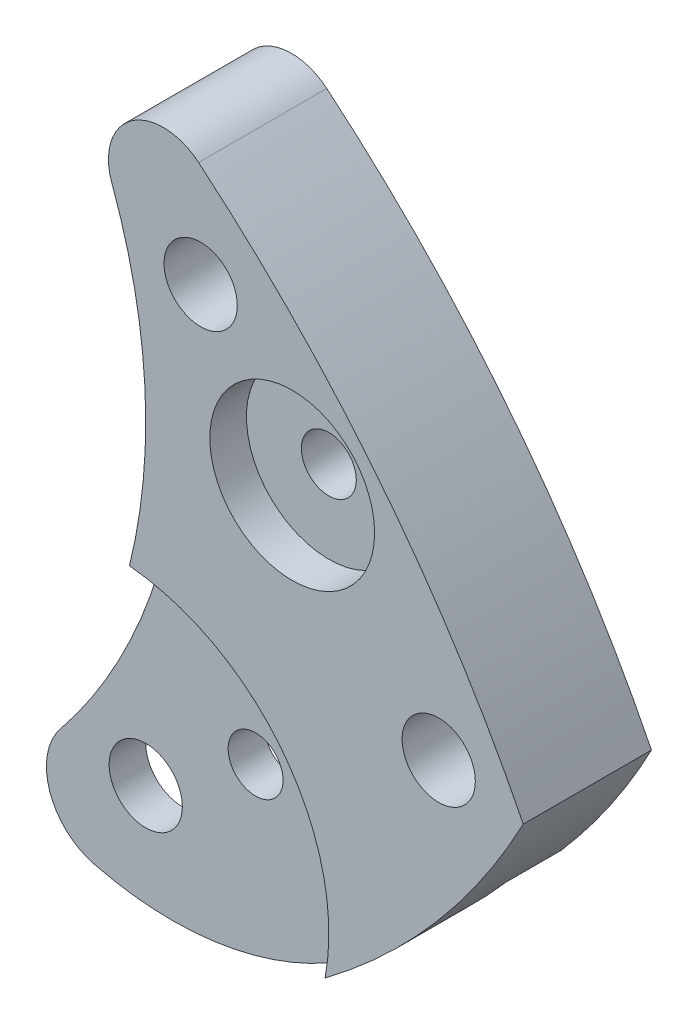
from build123d import *

# Parameters (mm, degrees)
CROQUIS1_R                     = 0.5
SALIENTE_EXTRUIR1_DEPTH        = 1.75
CROQUIS3_R                     = 4.5
CORTAR_EXTRUIR2_DEPTH          = 0.75
CORTAR_EXTRUIR3_DEPTH          = 0.75
CROQUIS5_R                     = 1.125
CORTAR_EXTRUIR4_DEPTH          = 0.5
TALADRO_ROSCADO_M1X0_251_D     = 0.75
CROQUIS8_R                     = 3
CORTAR_EXTRUIR5_DEPTH          = 0.5
TALADRO_ROSCADO_M1X0_252_D     = 0.75
TALADRO_ROSCADO_M1X0_252_DEPTH = 2
TALADRO_ROSCADO_M1X0_252_TIP   = 0.225322732


with BuildPart() as part:
    # Croquis1 → Saliente-Extruir1 (new body)
    with BuildSketch(Plane.XY):
        with BuildLine():
            ThreePointArc((8.834558852, 5.287471697), (10.400375853, 8.781625166), (10.037373186, 12.593333499))
            ThreePointArc((10.037373186, 12.593333499), (10.309088925, 13.465738911), (11.222055752, 13.428159394))
            ThreePointArc((11.222055752, 13.428159394), (13.727670201, 10.853620173), (15.654756656, 7.821674632))
            ThreePointArc((15.654756656, 7.821674632), (14.478080126, 6.085191999), (12.949014501, 4.649260976))
            ThreePointArc((12.949014501, 4.649260976), (11.201069025, 3.869086941), (9.287630024, 3.921394702))
            ThreePointArc((9.287630024, 3.921394702), (8.688101188, 4.480726783), (8.834558852, 5.287471697))
        make_face()
        with Locations((10, 5.2)):
            Circle(CROQUIS1_R, mode=Mode.SUBTRACT)
        with Locations((11.25, 12)):
            Circle(CROQUIS1_R, mode=Mode.SUBTRACT)
        with Locations((14.5, 8)):
            Circle(CROQUIS1_R, mode=Mode.SUBTRACT)
    extrude(amount=SALIENTE_EXTRUIR1_DEPTH)

    # Croquis3 → Cortar-Extruir2 (cut)
    with BuildSketch(Plane(origin=(0, 0, 0), x_dir=(-1, 0, 0), z_dir=(0, 0, -1))):
        with Locations((-10, 5.2)):
            Circle(CROQUIS3_R)
    extrude(amount=-CORTAR_EXTRUIR2_DEPTH, mode=Mode.SUBTRACT)

    # Croquis4 → Cortar-Extruir3 (cut)
    with BuildSketch(Plane(origin=(0, 0, 0), x_dir=(-1, 0, 0), z_dir=(0, 0, -1))):
        with BuildLine():
            ThreePointArc((-10.066948965, 13.181309844), (-10.613207176, 11.449681517), (-10.741563253, 9.63847766))
            ThreePointArc((-10.741563253, 9.63847766), (-10.61745437, 9.657437616), (-10.492864863, 9.672927925))
            ThreePointArc((-10.492864863, 9.672927925), (-10.410407993, 11.155791234), (-10.037373186, 12.593333499))
            ThreePointArc((-10.037373186, 12.593333499), (-9.992057529, 12.890344938), (-10.066948965, 13.181309844))
        make_face()
    extrude(amount=-CORTAR_EXTRUIR3_DEPTH, mode=Mode.SUBTRACT)

    # Croquis5 → Cortar-Extruir4 (cut)
    with BuildSketch(Plane.XY.offset(1.75)):
        with Locations((12.5, 10.25)):
            Circle(CROQUIS5_R)
    extrude(amount=-CORTAR_EXTRUIR4_DEPTH, mode=Mode.SUBTRACT)

    # Taladro roscado M1x0.251 (through all)
    with Locations(Plane.XY.offset(1.25)):
        with Locations((12.5, 10.25)):
            Hole(TALADRO_ROSCADO_M1X0_251_D / 2)

    # Croquis8 → Cortar-Extruir5 (cut)
    with BuildSketch(Plane.XY.offset(1.75)):
        with Locations((10, 5.2)):
            Circle(CROQUIS8_R)
    extrude(amount=-CORTAR_EXTRUIR5_DEPTH, mode=Mode.SUBTRACT)

    # Taladro roscado M1x0.252
    with Locations(Plane.XY.offset(1.25)):
        with Locations((11.5, 6.2)):
            Hole(TALADRO_ROSCADO_M1X0_252_D / 2, depth=TALADRO_ROSCADO_M1X0_252_DEPTH)
            with Locations((0, 0, -(TALADRO_ROSCADO_M1X0_252_DEPTH + TALADRO_ROSCADO_M1X0_252_TIP / 2))):  # 118° drill point
                Cone(0, TALADRO_ROSCADO_M1X0_252_D / 2, TALADRO_ROSCADO_M1X0_252_TIP, mode=Mode.SUBTRACT)


solid = part.part
